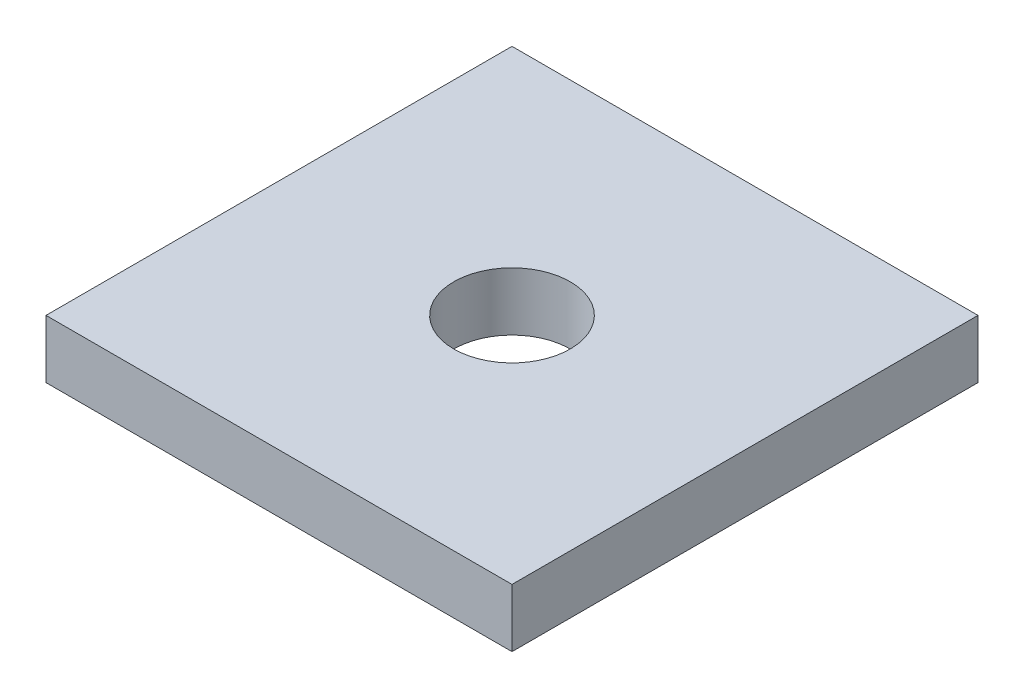
from build123d import *

# Parameters (mm, degrees)
SKETCH1_W           = 50.8
SKETCH1_H           = 50.8
SKETCH1_R           = 6.35
BOSS_EXTRUDE1_DEPTH = 6.35


with BuildPart() as part:
    # Sketch1 → Boss-Extrude1 (new body)
    with BuildSketch(Plane(origin=(0, 0, 0), x_dir=(1, 0, 0), z_dir=(0, 1, 0))):
        Rectangle(SKETCH1_W, SKETCH1_H)
        Circle(SKETCH1_R, mode=Mode.SUBTRACT)
    extrude(amount=BOSS_EXTRUDE1_DEPTH)


solid = part.part
